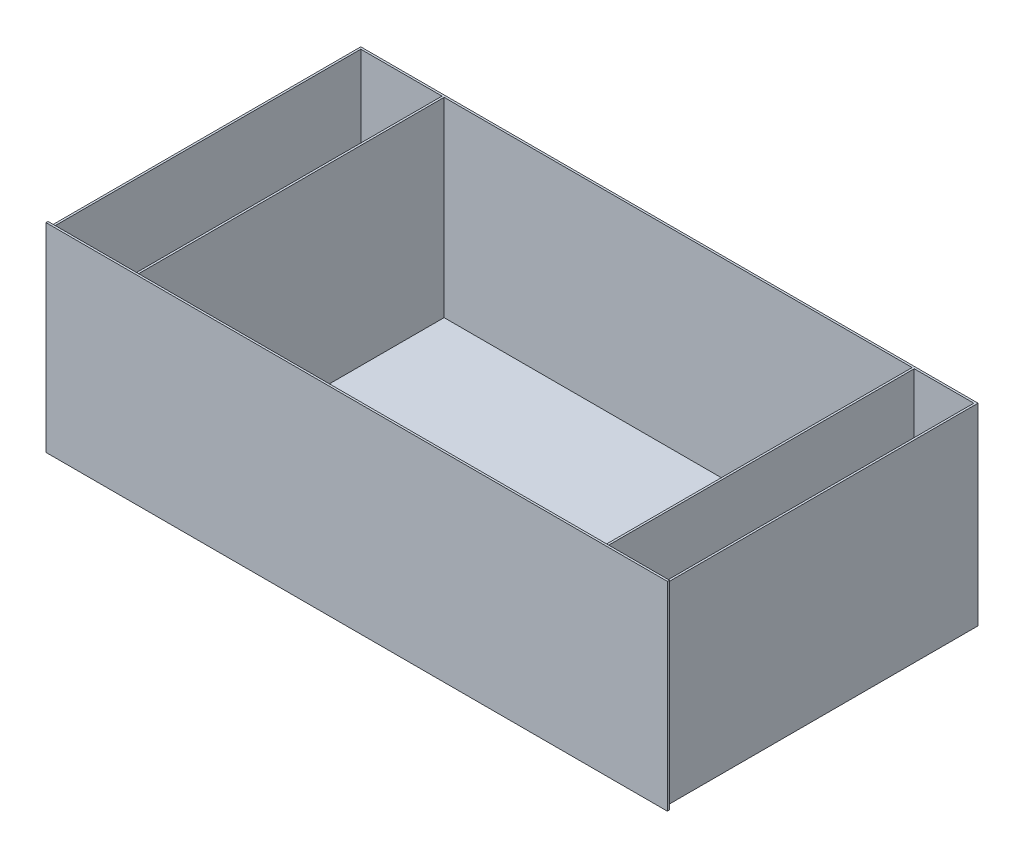
from build123d import *

# Parameters (mm, degrees)
SKETCH1_W           = 1208
SKETCH1_H           = 387
BOSS_EXTRUDE1_DEPTH = 4
SKETCH2_W           = 1200
SKETCH2_H           = 604
BOSS_EXTRUDE2_DEPTH = 375
SKETCH3_W           = 158
SKETCH3_H           = 596
SKETCH3_W_2         = 910
SKETCH3_W_3         = 116
CUT_EXTRUDE1_DEPTH  = 371


with BuildPart() as part:
    # Sketch1 → Boss-Extrude1 (new body)
    with BuildSketch(Plane.XY):
        Rectangle(SKETCH1_W, SKETCH1_H)
    extrude(amount=BOSS_EXTRUDE1_DEPTH)

    # Sketch2 → Boss-Extrude2 (add)
    with BuildSketch(Plane(origin=(0, -187.5, 0), x_dir=(1, 0, 0), z_dir=(0, 1, 0))):
        with Locations((0, 302)):
            Rectangle(SKETCH2_W, SKETCH2_H)
    extrude(amount=BOSS_EXTRUDE2_DEPTH)

    # Sketch3 → Cut-Extrude1 (cut)
    with BuildSketch(Plane(origin=(0, 187.5, 0), x_dir=(1, 0, 0), z_dir=(0, 1, 0))):
        with Locations((-517, 302)):
            Rectangle(SKETCH3_W, SKETCH3_H)
        with Locations((21, 302)):
            Rectangle(SKETCH3_W_2, SKETCH3_H)
        with Locations((538, 302)):
            Rectangle(SKETCH3_W_3, SKETCH3_H)
    extrude(amount=-CUT_EXTRUDE1_DEPTH, mode=Mode.SUBTRACT)


solid = part.part
